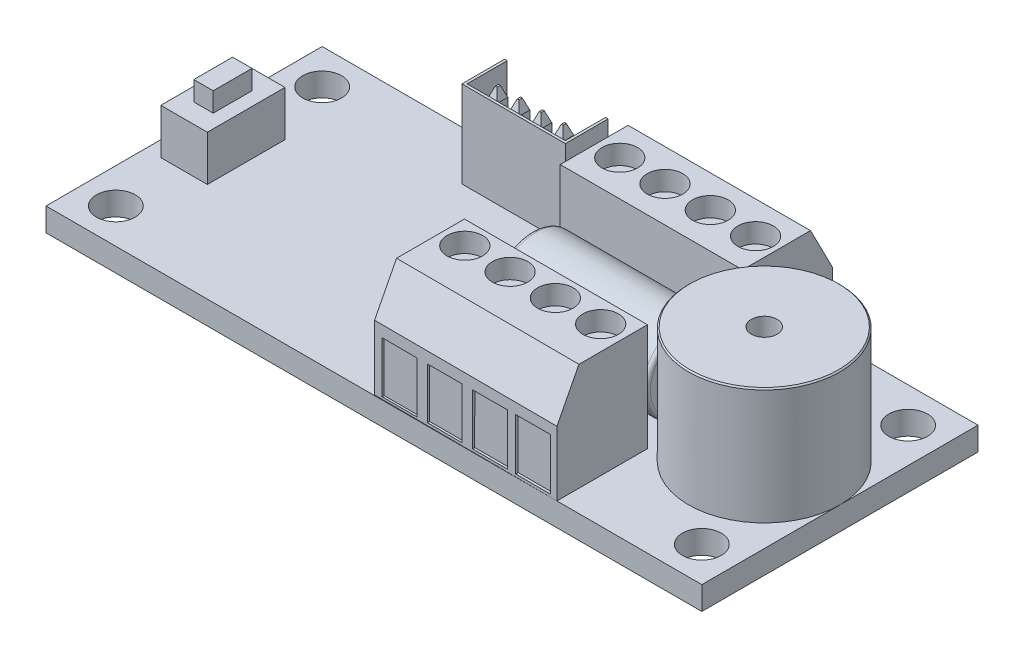
from build123d import *

# Parameters (mm, degrees)
SKETCH1_W              = 50.7
SKETCH1_H              = 21.35
SKETCH1_R              = 1.5
BOSS_EXTRUDE1_DEPTH    = 1.8
SKETCH2_R              = 5.85
BOSS_EXTRUDE2_DEPTH    = 9
SKETCH3_R              = 1
CUT_EXTRUDE1_DEPTH     = 8
CHAMFER1_SIZE          = 0.1
SKETCH4_R              = 3.25
BOSS_EXTRUDE3_DEPTH    = 12.1
FILLET1_R              = 0.3
FILLET2_R              = 0.3
SKETCH5_W              = 3.6
SKETCH5_H              = 6
BOSS_EXTRUDE4_DEPTH    = 3.5
SKETCH6_W              = 1.5
SKETCH6_H              = 3
BOSS_EXTRUDE5_DEPTH    = 1.5
SKETCH7_W              = 14.1
SKETCH7_H              = 6.95
BOSS_EXTRUDE6_DEPTH    = 8.3
CHAMFER2_SIZE          = 3.3
CHAMFER2_SIZE2         = 1.7
CHAMFER3_SIZE          = 1.7
CHAMFER3_SIZE2         = 3.3
SKETCH8_W              = 2.7
SKETCH8_H              = 4
CUT_EXTRUDE2_DEPTH     = 0.2
SKETCH9_R              = 1.375
CUT_EXTRUDE3_DEPTH     = 1.5
SKETCH10_R             = 1.375
CUT_EXTRUDE4_DEPTH     = 1.5
SKETCH11_W             = 2.7
SKETCH11_H             = 3.95
CUT_EXTRUDE5_DEPTH     = 0.2
SKETCH13_W             = 8
SKETCH13_H             = 3.3
BOSS_EXTRUDE7_DEPTH    = 2.7
SKETCH14_W             = 0.725453277
SKETCH14_H             = 0.820771089
BOSS_EXTRUDE8_DEPTH    = 4
CHAMFER4_SIZE          = 0.8
CHAMFER4_SIZE2         = 0.291176187
CHAMFER4_PART_2_SIZE   = 0.8
CHAMFER4_PART_2_SIZE2  = 0.291176187
CHAMFER4_PART_3_SIZE   = 0.8
CHAMFER4_PART_3_SIZE2  = 0.291176187
CHAMFER4_PART_4_SIZE   = 0.8
CHAMFER4_PART_4_SIZE2  = 0.291176187
CHAMFER4_PART_5_SIZE   = 0.8
CHAMFER4_PART_5_SIZE2  = 0.291176187
CHAMFER4_PART_6_SIZE   = 0.8
CHAMFER4_PART_6_SIZE2  = 0.291176187
CHAMFER4_PART_7_SIZE   = 0.8
CHAMFER4_PART_7_SIZE2  = 0.291176187
CHAMFER4_PART_8_SIZE   = 0.8
CHAMFER4_PART_8_SIZE2  = 0.291176187
CHAMFER4_PART_9_SIZE   = 0.8
CHAMFER4_PART_9_SIZE2  = 0.291176187
CHAMFER4_PART_10_SIZE  = 0.8
CHAMFER4_PART_10_SIZE2 = 0.291176187
CHAMFER4_PART_11_SIZE  = 0.8
CHAMFER4_PART_11_SIZE2 = 0.291176187
CHAMFER4_PART_12_SIZE  = 0.8
CHAMFER4_PART_12_SIZE2 = 0.291176187
CHAMFER4_PART_13_SIZE  = 0.8
CHAMFER4_PART_13_SIZE2 = 0.291176187
CHAMFER4_PART_14_SIZE  = 0.8
CHAMFER4_PART_14_SIZE2 = 0.291176187
CHAMFER4_PART_15_SIZE  = 0.8
CHAMFER4_PART_15_SIZE2 = 0.291176187
CHAMFER4_PART_16_SIZE  = 0.8
CHAMFER4_PART_16_SIZE2 = 0.291176187


with BuildPart() as part:
    # Sketch1 → Boss-Extrude1 (new body)
    with BuildSketch(Plane(origin=(0, 0, 0), x_dir=(1, 0, 0), z_dir=(0, 1, 0))):
        with Locations((2.788998035, -0.31586444)):
            Rectangle(SKETCH1_W, SKETCH1_H)
        with Locations(Location((-19.861001965, 7.65913556, 0), (0, 0, 270))):  # turned: the seam where the file's is
            Circle(SKETCH1_R, mode=Mode.SUBTRACT)
        with Locations(Location((-19.861001965, -8.29086444, 0), (0, 0, 270))):  # turned: the seam where the file's is
            Circle(SKETCH1_R, mode=Mode.SUBTRACT)
        with Locations(Location((25.438998035, 7.65913556, 0), (0, 0, 270))):  # turned: the seam where the file's is
            Circle(SKETCH1_R, mode=Mode.SUBTRACT)
        with Locations(Location((25.438998035, -8.29086444, 0), (0, 0, 270))):  # turned: the seam where the file's is
            Circle(SKETCH1_R, mode=Mode.SUBTRACT)
    extrude(amount=BOSS_EXTRUDE1_DEPTH)

    # Sketch2 → Boss-Extrude2 (add)
    with BuildSketch(Plane(origin=(0, 1.8, 0), x_dir=(1, 0, 0), z_dir=(0, 1, 0))):
        with Locations((22.288998035, -0.31586444)):
            Circle(SKETCH2_R)
    extrude(amount=BOSS_EXTRUDE2_DEPTH)

    # Sketch3 → Cut-Extrude1 (cut)
    with BuildSketch(Plane(origin=(0, 10.8, 0), x_dir=(1, 0, 0), z_dir=(0, 1, 0))):
        with Locations(Location((22.288998035, -0.31586444, 0), (0, 0, 270))):  # turned: the seam where the file's is
            Circle(SKETCH3_R)
    extrude(amount=-CUT_EXTRUDE1_DEPTH, mode=Mode.SUBTRACT)

    # Chamfer1
    chamfer1_edges = [part.edges().sort_by_distance(p)[0] for p in [
        (16.438998035, 10.8, 0.31586444),
    ]]
    chamfer(chamfer1_edges, length=CHAMFER1_SIZE)

    # Sketch5 → Boss-Extrude4 (add)
    with BuildSketch(Plane(origin=(0, 1.8, 0), x_dir=(1, 0, 0), z_dir=(0, 1, 0))):
        with Locations((-19.561001965, -0.31586444)):
            Rectangle(SKETCH5_W, SKETCH5_H)
    extrude(amount=BOSS_EXTRUDE4_DEPTH)

    # Sketch6 → Boss-Extrude5 (add)
    with BuildSketch(Plane(origin=(0, 5.3, 0), x_dir=(1, 0, 0), z_dir=(0, 1, 0))):
        with Locations((-19.561001965, -0.31586444)):
            Rectangle(SKETCH6_W, SKETCH6_H)
    extrude(amount=BOSS_EXTRUDE5_DEPTH)

    # Sketch7 → Boss-Extrude6 (add)
    with BuildSketch(Plane(origin=(0, 1.8, 0), x_dir=(1, 0, 0), z_dir=(0, 1, 0))):
        with Locations((9.888998035, 6.83413556)):
            Rectangle(SKETCH7_W, SKETCH7_H)
        Polygon((16.938998035, -10.99086444), (2.788998035, -10.94086444), (2.788998035, -3.99086444), (16.938998035, -3.99086444), align=None)
    extrude(amount=BOSS_EXTRUDE6_DEPTH)

    # Chamfer2
    chamfer2_edges = [part.edges().sort_by_distance(p)[0] for p in [
        (9.888998035, 10.1, -10.30913556),
    ]]
    chamfer2_side = [part.faces().sort_by_distance(p)[0] for p in [
        (9.888998035, 5.95, -10.30913556),
    ]]
    chamfer(chamfer2_edges, length=CHAMFER2_SIZE, length2=CHAMFER2_SIZE2, reference=chamfer2_side[0])

    # Chamfer3
    chamfer3_edges = [part.edges().sort_by_distance(p)[0] for p in [
        (9.863998035, 10.1, 10.96586444),
    ]]
    chamfer3_side = [part.faces().sort_by_distance(p)[0] for p in [
        (9.872450843, 10.1, 7.478379374),
    ]]
    chamfer(chamfer3_edges, length=CHAMFER3_SIZE, length2=CHAMFER3_SIZE2, reference=chamfer3_side[0])

    # Sketch8 → Cut-Extrude2 (cut)
    with BuildSketch(Plane(origin=(0, 0, -10.35913556), x_dir=(-1, 0, 0), z_dir=(0, 0, -1))):
        with Locations((-15.088998035, 4.3)):
            Rectangle(SKETCH8_W, SKETCH8_H)
        with Locations((-11.588998035, 4.3)):
            Rectangle(SKETCH8_W, SKETCH8_H)
        with Locations((-8.088998035, 4.3)):
            Rectangle(SKETCH8_W, SKETCH8_H)
        with Locations((-4.588998035, 4.3)):
            Rectangle(SKETCH8_W, SKETCH8_H)
    extrude(amount=-CUT_EXTRUDE2_DEPTH, mode=Mode.SUBTRACT)

    # Sketch9 → Cut-Extrude3 (cut)
    with BuildSketch(Plane(origin=(0, 10.1, 0), x_dir=(1, 0, 0), z_dir=(0, 1, 0))):
        with Locations(Location((15.188998035, 6.115447811, 0), (0, 0, 270))):  # turned: the seam where the file's is
            Circle(SKETCH9_R)
        with Locations(Location((11.688998035, 6.115447811, 0), (0, 0, 270))):  # turned: the seam where the file's is
            Circle(SKETCH9_R)
        with Locations(Location((8.188998035, 6.115447811, 0), (0, 0, 270))):  # turned: the seam where the file's is
            Circle(SKETCH9_R)
        with Locations(Location((4.688998035, 6.115447811, 0), (0, 0, 270))):  # turned: the seam where the file's is
            Circle(SKETCH9_R)
    extrude(amount=-CUT_EXTRUDE3_DEPTH, mode=Mode.SUBTRACT)

    # Sketch10 → Cut-Extrude4 (cut)
    with BuildSketch(Plane(origin=(0, 10.1, 0), x_dir=(1, 0, 0), z_dir=(0, 1, 0))):
        with Locations(Location((15.088998035, -5.761723228, 0), (0, 0, 270))):  # turned: the seam where the file's is
            Circle(SKETCH10_R)
        with Locations(Location((8.088998035, -5.761723228, 0), (0, 0, 270))):  # turned: the seam where the file's is
            Circle(SKETCH10_R)
        with Locations(Location((4.588998035, -5.761723228, 0), (0, 0, 270))):  # turned: the seam where the file's is
            Circle(SKETCH10_R)
        with Locations(Location((11.588998035, -5.761723228, 0), (0, 0, 270))):  # turned: the seam where the file's is
            Circle(SKETCH10_R)
    extrude(amount=-CUT_EXTRUDE4_DEPTH, mode=Mode.SUBTRACT)

    # Sketch11 → Cut-Extrude5 (cut)
    with BuildSketch(Plane.XY.offset(10.99086444)):
        Polygon((6.884623692, 5.931015834), (6.884150513, 2), (9.584150513, 2), (9.584496665, 5.949534905), align=None)
        Polygon((10.384459028, 5.955022038), (10.384150513, 2), (13.084150513, 2), (13.084332001, 5.973541109), align=None)
        Polygon((13.739148715, 5.978032653), (13.738998035, 2), (16.438998035, 2), (16.438998035, 5.996551562), align=None)
        with Locations((4.734788356, 3.950529573)):
            Rectangle(SKETCH11_W, SKETCH11_H)
    extrude(amount=-CUT_EXTRUDE5_DEPTH, mode=Mode.SUBTRACT)

    # Sketch13 → Boss-Extrude7 (add)
    with BuildSketch(Plane(origin=(0, 1.8, 0), x_dir=(1, 0, 0), z_dir=(0, 1, 0))):
        with Locations((-3.961001965, 8.20913556)):
            Rectangle(SKETCH13_W, SKETCH13_H)
    extrude(amount=BOSS_EXTRUDE7_DEPTH)

    # Sketch14 → Boss-Extrude8 (add)
    with BuildSketch(Plane(origin=(0, 4.5, 0), x_dir=(1, 0, 0), z_dir=(0, 1, 0))):
        Polygon((-0.161001965, 9.85913556), (0.038998035, 9.85913556), (0.038998035, 6.55913556), (-7.961001965, 6.55913556), (-7.961001965, 9.85913556), (-7.761001965, 9.85913556), (-7.761001965, 6.75913556), (-0.161001965, 6.75913556), align=None)
        with Locations((-6.445906453, 7.824779453)):
            Rectangle(SKETCH14_W, SKETCH14_H)
        with Locations((-4.745906452, 7.824779453)):
            Rectangle(SKETCH14_W, SKETCH14_H)
        with Locations((-3.045906453, 7.824779453)):
            Rectangle(SKETCH14_W, SKETCH14_H)
        with Locations((-1.345906452, 7.824779453)):
            Rectangle(SKETCH14_W, SKETCH14_H)
    extrude(amount=BOSS_EXTRUDE8_DEPTH)

    # Chamfer4
    chamfer4_edges = [part.edges().sort_by_distance(p)[0] for p in [
        (-6.083179814, 8.5, -7.824779453),
    ]]
    chamfer4_side = [part.faces().sort_by_distance(p)[0] for p in [
        (-6.083179814, 6.5, -7.824779453),
    ]]
    chamfer(chamfer4_edges, length=CHAMFER4_SIZE, length2=CHAMFER4_SIZE2, reference=chamfer4_side[0])

    # Chamfer4 part 2
    chamfer4_part_2_edges = [part.edges().sort_by_distance(p)[0] for p in [
        (-6.445906453, 8.5, -8.235164998),
    ]]
    chamfer4_part_2_side = [part.faces().sort_by_distance(p)[0] for p in [
        (-6.445906453, 6.5, -8.235164998),
    ]]
    chamfer(chamfer4_part_2_edges, length=CHAMFER4_PART_2_SIZE, length2=CHAMFER4_PART_2_SIZE2, reference=chamfer4_part_2_side[0])

    # Chamfer4 part 3
    chamfer4_part_3_edges = [part.edges().sort_by_distance(p)[0] for p in [
        (-6.808633091, 8.5, -7.824779453),
    ]]
    chamfer4_part_3_side = [part.faces().sort_by_distance(p)[0] for p in [
        (-6.808633091, 6.5, -7.824779453),
    ]]
    chamfer(chamfer4_part_3_edges, length=CHAMFER4_PART_3_SIZE, length2=CHAMFER4_PART_3_SIZE2, reference=chamfer4_part_3_side[0])

    # Chamfer4 part 4
    chamfer4_part_4_edges = [part.edges().sort_by_distance(p)[0] for p in [
        (-6.445906453, 8.5, -7.414393909),
    ]]
    chamfer4_part_4_side = [part.faces().sort_by_distance(p)[0] for p in [
        (-6.445906453, 6.5, -7.414393909),
    ]]
    chamfer(chamfer4_part_4_edges, length=CHAMFER4_PART_4_SIZE, length2=CHAMFER4_PART_4_SIZE2, reference=chamfer4_part_4_side[0])

    # Chamfer4 part 5
    chamfer4_part_5_edges = [part.edges().sort_by_distance(p)[0] for p in [
        (-4.745906453, 8.5, -8.235164998),
    ]]
    chamfer4_part_5_side = [part.faces().sort_by_distance(p)[0] for p in [
        (-4.745906453, 6.5, -8.235164998),
    ]]
    chamfer(chamfer4_part_5_edges, length=CHAMFER4_PART_5_SIZE, length2=CHAMFER4_PART_5_SIZE2, reference=chamfer4_part_5_side[0])

    # Chamfer4 part 6
    chamfer4_part_6_edges = [part.edges().sort_by_distance(p)[0] for p in [
        (-5.108633091, 8.5, -7.824779453),
    ]]
    chamfer4_part_6_side = [part.faces().sort_by_distance(p)[0] for p in [
        (-5.108633091, 6.5, -7.824779453),
    ]]
    chamfer(chamfer4_part_6_edges, length=CHAMFER4_PART_6_SIZE, length2=CHAMFER4_PART_6_SIZE2, reference=chamfer4_part_6_side[0])

    # Chamfer4 part 7
    chamfer4_part_7_edges = [part.edges().sort_by_distance(p)[0] for p in [
        (-4.745906453, 8.5, -7.414393909),
    ]]
    chamfer4_part_7_side = [part.faces().sort_by_distance(p)[0] for p in [
        (-4.745906453, 6.5, -7.414393909),
    ]]
    chamfer(chamfer4_part_7_edges, length=CHAMFER4_PART_7_SIZE, length2=CHAMFER4_PART_7_SIZE2, reference=chamfer4_part_7_side[0])

    # Chamfer4 part 8
    chamfer4_part_8_edges = [part.edges().sort_by_distance(p)[0] for p in [
        (-4.383179814, 8.5, -7.824779453),
    ]]
    chamfer4_part_8_side = [part.faces().sort_by_distance(p)[0] for p in [
        (-4.383179814, 6.5, -7.824779453),
    ]]
    chamfer(chamfer4_part_8_edges, length=CHAMFER4_PART_8_SIZE, length2=CHAMFER4_PART_8_SIZE2, reference=chamfer4_part_8_side[0])

    # Chamfer4 part 9
    chamfer4_part_9_edges = [part.edges().sort_by_distance(p)[0] for p in [
        (-3.045906453, 8.5, -8.235164998),
    ]]
    chamfer4_part_9_side = [part.faces().sort_by_distance(p)[0] for p in [
        (-3.045906453, 6.5, -8.235164998),
    ]]
    chamfer(chamfer4_part_9_edges, length=CHAMFER4_PART_9_SIZE, length2=CHAMFER4_PART_9_SIZE2, reference=chamfer4_part_9_side[0])

    # Chamfer4 part 10
    chamfer4_part_10_edges = [part.edges().sort_by_distance(p)[0] for p in [
        (-3.408633091, 8.5, -7.824779453),
    ]]
    chamfer4_part_10_side = [part.faces().sort_by_distance(p)[0] for p in [
        (-3.408633091, 6.5, -7.824779453),
    ]]
    chamfer(chamfer4_part_10_edges, length=CHAMFER4_PART_10_SIZE, length2=CHAMFER4_PART_10_SIZE2, reference=chamfer4_part_10_side[0])

    # Chamfer4 part 11
    chamfer4_part_11_edges = [part.edges().sort_by_distance(p)[0] for p in [
        (-3.045906453, 8.5, -7.414393909),
    ]]
    chamfer4_part_11_side = [part.faces().sort_by_distance(p)[0] for p in [
        (-3.045906453, 6.5, -7.414393909),
    ]]
    chamfer(chamfer4_part_11_edges, length=CHAMFER4_PART_11_SIZE, length2=CHAMFER4_PART_11_SIZE2, reference=chamfer4_part_11_side[0])

    # Chamfer4 part 12
    chamfer4_part_12_edges = [part.edges().sort_by_distance(p)[0] for p in [
        (-2.683179814, 8.5, -7.824779453),
    ]]
    chamfer4_part_12_side = [part.faces().sort_by_distance(p)[0] for p in [
        (-2.683179814, 6.5, -7.824779453),
    ]]
    chamfer(chamfer4_part_12_edges, length=CHAMFER4_PART_12_SIZE, length2=CHAMFER4_PART_12_SIZE2, reference=chamfer4_part_12_side[0])

    # Chamfer4 part 13
    chamfer4_part_13_edges = [part.edges().sort_by_distance(p)[0] for p in [
        (-1.345906453, 8.5, -8.235164998),
    ]]
    chamfer4_part_13_side = [part.faces().sort_by_distance(p)[0] for p in [
        (-1.345906453, 6.5, -8.235164998),
    ]]
    chamfer(chamfer4_part_13_edges, length=CHAMFER4_PART_13_SIZE, length2=CHAMFER4_PART_13_SIZE2, reference=chamfer4_part_13_side[0])

    # Chamfer4 part 14
    chamfer4_part_14_edges = [part.edges().sort_by_distance(p)[0] for p in [
        (-1.708633091, 8.5, -7.824779453),
    ]]
    chamfer4_part_14_side = [part.faces().sort_by_distance(p)[0] for p in [
        (-1.708633091, 6.5, -7.824779453),
    ]]
    chamfer(chamfer4_part_14_edges, length=CHAMFER4_PART_14_SIZE, length2=CHAMFER4_PART_14_SIZE2, reference=chamfer4_part_14_side[0])

    # Chamfer4 part 15
    chamfer4_part_15_edges = [part.edges().sort_by_distance(p)[0] for p in [
        (-1.345906453, 8.5, -7.414393909),
    ]]
    chamfer4_part_15_side = [part.faces().sort_by_distance(p)[0] for p in [
        (-1.345906453, 6.5, -7.414393909),
    ]]
    chamfer(chamfer4_part_15_edges, length=CHAMFER4_PART_15_SIZE, length2=CHAMFER4_PART_15_SIZE2, reference=chamfer4_part_15_side[0])

    # Chamfer4 part 16
    chamfer4_part_16_edges = [part.edges().sort_by_distance(p)[0] for p in [
        (-0.983179814, 8.5, -7.824779453),
    ]]
    chamfer4_part_16_side = [part.faces().sort_by_distance(p)[0] for p in [
        (-0.983179814, 6.5, -7.824779453),
    ]]
    chamfer(chamfer4_part_16_edges, length=CHAMFER4_PART_16_SIZE, length2=CHAMFER4_PART_16_SIZE2, reference=chamfer4_part_16_side[0])


with BuildPart() as body_2:
    # Sketch4 → Boss-Extrude3 (new body)
    with BuildSketch(Plane.ZY.offset(-16.438998035)):
        with Locations((0.31086444, 5.05)):
            Circle(SKETCH4_R)
    extrude(amount=BOSS_EXTRUDE3_DEPTH)

    # Fillet1
    fillet1_edges = [body_2.edges().sort_by_distance(p)[0] for p in [
        (16.438998035, 5.05, -2.93913556),
    ]]
    fillet(fillet1_edges, radius=FILLET1_R)

    # Fillet2
    fillet2_edges = [body_2.edges().sort_by_distance(p)[0] for p in [
        (4.338998035, 5.05, -2.93913556),
    ]]
    fillet(fillet2_edges, radius=FILLET2_R)


solid = Compound([part.part, body_2.part])
